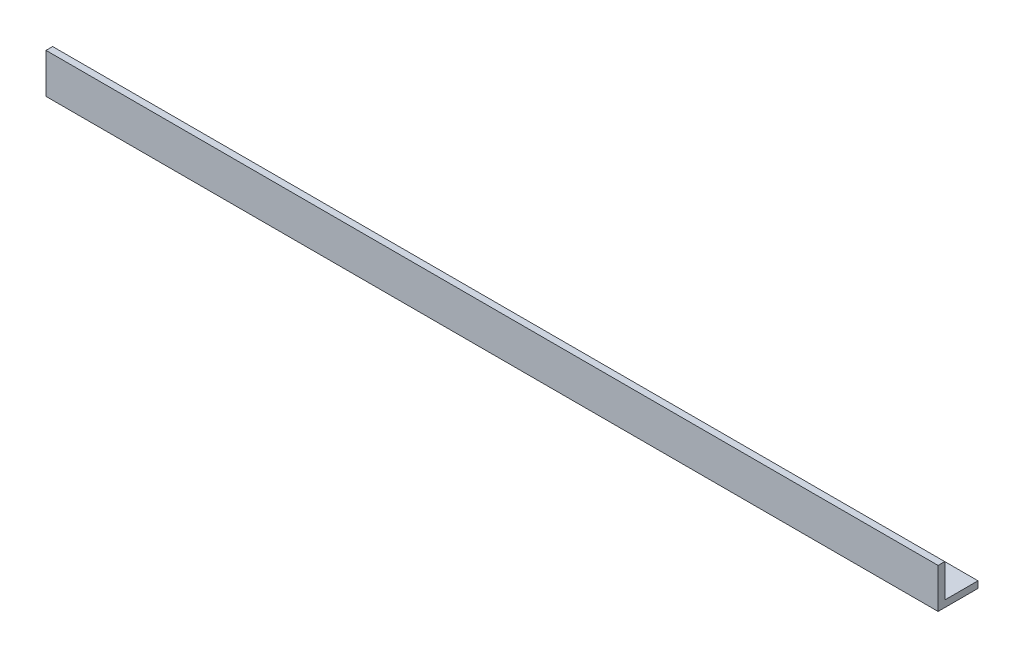
from build123d import *

# Parameters (mm, degrees)
BOSS_EXTRUDE1_DEPTH = 426


with BuildPart() as part:
    # Sketch1 → Boss-Extrude1 (new body)
    with BuildSketch(Plane(origin=(0, 0, 0), x_dir=(0, 0, -1), z_dir=(1, 0, 0))):
        Polygon((0, 0), (0, 19.05), (3.175, 19.05), (3.175, 3.175), (19.05, 3.175), (19.05, 0), align=None)
    extrude(amount=BOSS_EXTRUDE1_DEPTH)


solid = part.part
